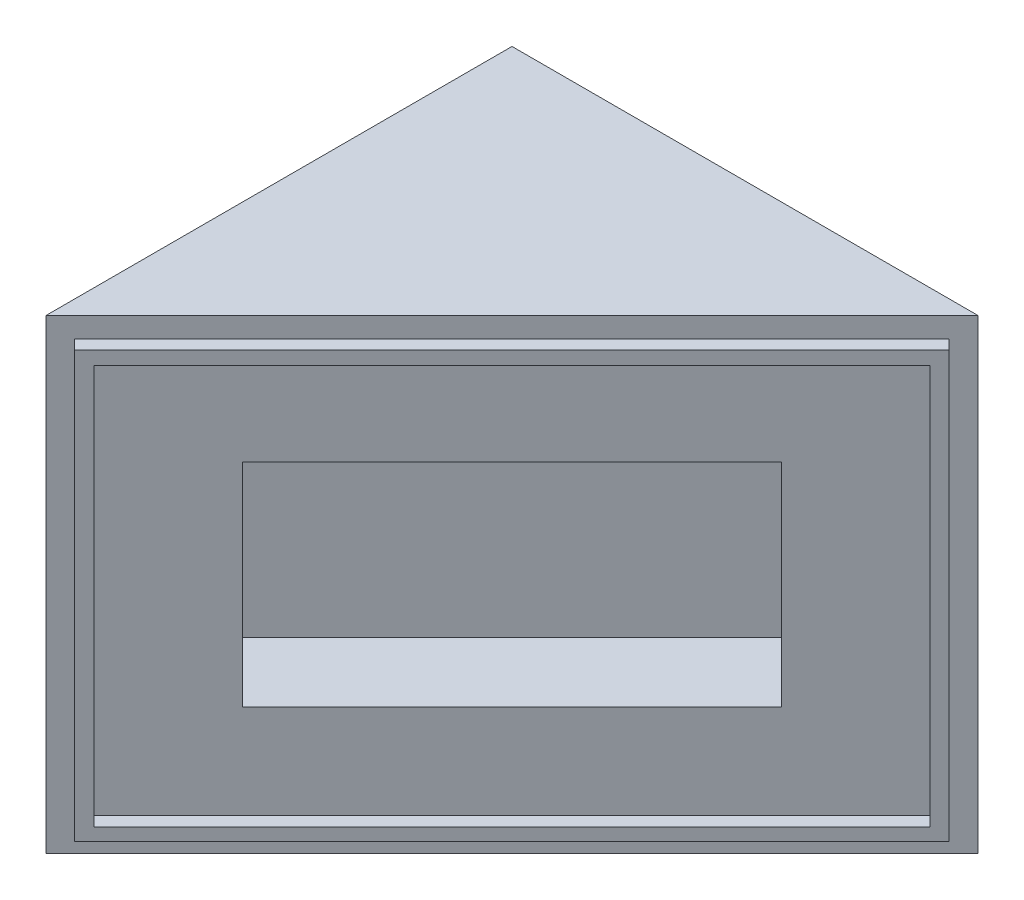
from build123d import *

# Parameters (mm, degrees)
SKETCH1_W           = 69.85
SKETCH1_H           = 69.85
BOSS_EXTRUDE1_DEPTH = 69.85
CUT_EXTRUDE2_DEPTH  = 100
SKETCH3_W           = 92.734817332
SKETCH3_H           = 63.802
SKETCH3_W_2         = 88.628817955
SKETCH3_H_2         = 59.858884928
BOSS_EXTRUDE2_DEPTH = 2.032
SKETCH4_W           = 57.15
SKETCH4_H           = 31.75
CUT_EXTRUDE3_DEPTH  = 12.7


with BuildPart() as part:
    # Sketch1 → Boss-Extrude1 (new body)
    with BuildSketch(Plane(origin=(0, 0, 0), x_dir=(1, 0, 0), z_dir=(0, 1, 0))):
        with Locations((34.925, 34.925)):
            Rectangle(SKETCH1_W, SKETCH1_H)
    extrude(amount=BOSS_EXTRUDE1_DEPTH)

    # Sketch2 → Cut-Extrude2 (cut)
    with BuildSketch(Plane(origin=(0, 0, 0), x_dir=(0.707106781, 0, -0.707106781), z_dir=(0.707106781, 0, 0.707106781))):
        Polygon((98.782817332, 69.85), (98.782817332, 0), (49.391408666, 0), (0, 0), (0, 69.85), (49.391408666, 69.85), align=None)
    extrude(amount=CUT_EXTRUDE2_DEPTH, mode=Mode.SUBTRACT)

    # Sketch3 → Boss-Extrude2 (add)
    with BuildSketch(Plane(origin=(0, 0, 0), x_dir=(0.707106781, 0, -0.707106781), z_dir=(0.707106781, 0, 0.707106781))):
        with Locations((49.367408666, 34.901)):
            Rectangle(SKETCH3_W, SKETCH3_H)
        with Locations((49.388408355, 34.840557536)):
            Rectangle(SKETCH3_W_2, SKETCH3_H_2, mode=Mode.SUBTRACT)
    extrude(amount=BOSS_EXTRUDE2_DEPTH)

    # Sketch4 → Cut-Extrude3 (cut)
    with BuildSketch(Plane(origin=(0, 0, 0), x_dir=(0.707106781, 0, -0.707106781), z_dir=(0.707106781, 0, 0.707106781))):
        with Locations((49.391408666, 34.925)):
            Rectangle(SKETCH4_W, SKETCH4_H)
    extrude(amount=-CUT_EXTRUDE3_DEPTH, mode=Mode.SUBTRACT)


solid = part.part
